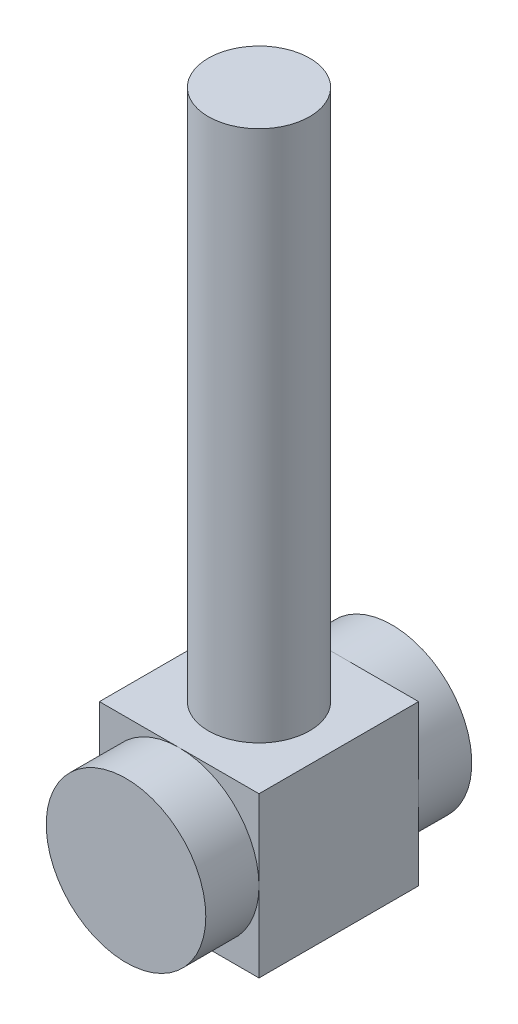
from build123d import *

# Parameters (mm, degrees)
SKETCH1_W           = 30
SKETCH1_H           = 30
BOSS_EXTRUDE2_DEPTH = 15
SKETCH2_R           = 15
BOSS_EXTRUDE3_DEPTH = 10
SKETCH3_R           = 15
BOSS_EXTRUDE4_DEPTH = 10
SKETCH4_R           = 9.528333781
CUT_EXTRUDE1_DEPTH  = 31
BOSS_EXTRUDE5_START = -30
SKETCH5_R           = 9.528333781
BOSS_EXTRUDE5_DEPTH = 130


with BuildPart() as part:
    # Sketch1 → Boss-Extrude2 (new body, symmetric)
    with BuildSketch(Plane.XY):
        Rectangle(SKETCH1_W, SKETCH1_H)
    extrude(amount=BOSS_EXTRUDE2_DEPTH, both=True)

    # Sketch2 → Boss-Extrude3 (add)
    with BuildSketch(Plane.XY.offset(15)):
        Circle(SKETCH2_R)
    extrude(amount=BOSS_EXTRUDE3_DEPTH)

    # Sketch3 → Boss-Extrude4 (add)
    with BuildSketch(Plane(origin=(0, 0, -15), x_dir=(-1, 0, 0), z_dir=(0, 0, -1))):
        Circle(SKETCH3_R)
    extrude(amount=BOSS_EXTRUDE4_DEPTH)

    # Sketch4 → Cut-Extrude1 (cut, through all)
    with BuildSketch(Plane(origin=(0, 15, 0), x_dir=(1, 0, 0), z_dir=(0, 1, 0))):
        Circle(SKETCH4_R)
    extrude(amount=-CUT_EXTRUDE1_DEPTH, mode=Mode.SUBTRACT)

    # Sketch5 → Boss-Extrude5 (add)
    with BuildSketch(Plane(origin=(0, 15, 0), x_dir=(1, 0, 0), z_dir=(0, 1, 0)).offset(BOSS_EXTRUDE5_START)):
        Circle(SKETCH5_R)
    extrude(amount=BOSS_EXTRUDE5_DEPTH)


solid = part.part
